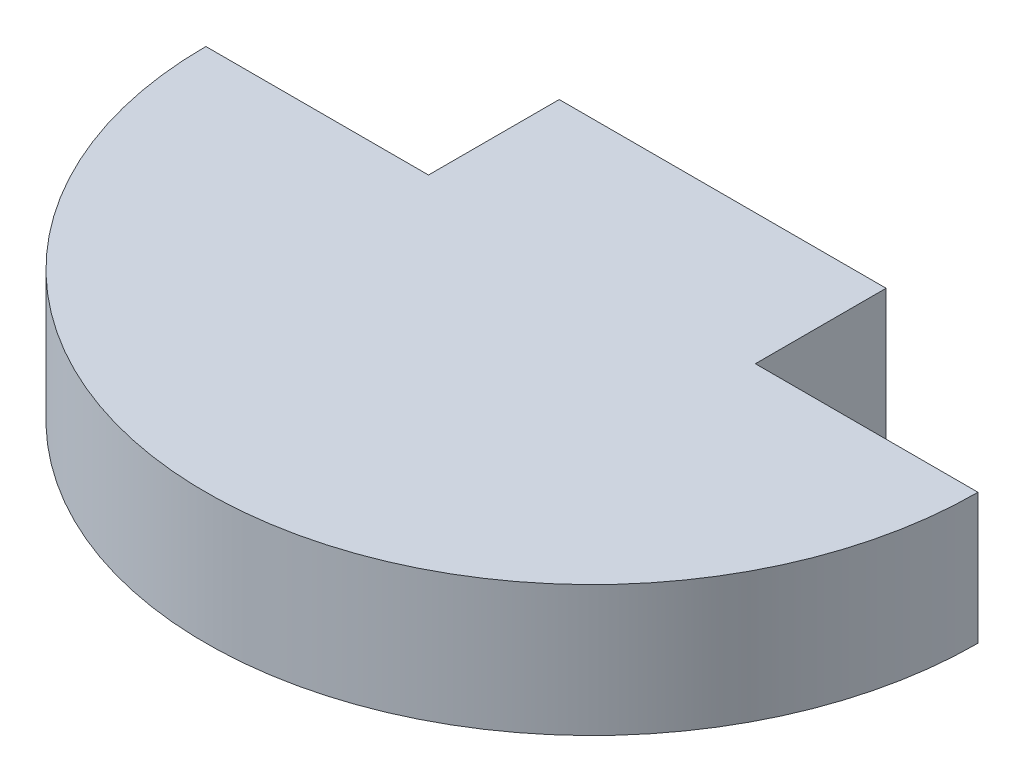
from build123d import *

# Parameters (mm, degrees)
SKETCH1_R           = 15
BOSS_EXTRUDE1_DEPTH = 5.08
SKETCH2_W           = 841.216063822
SKETCH2_H           = 769.249769976
CUT_EXTRUDE1_DEPTH  = 5.08
SKETCH3_W           = 12.7
SKETCH3_H           = 5.08
BOSS_EXTRUDE2_DEPTH = 5.08


with BuildPart() as part:
    # Sketch1 → Boss-Extrude1 (new body)
    with BuildSketch(Plane(origin=(0, 0, 0), x_dir=(1, 0, 0), z_dir=(0, 1, 0))):
        Circle(SKETCH1_R)
    extrude(amount=BOSS_EXTRUDE1_DEPTH)

    # Sketch2 → Cut-Extrude1 (cut)
    with BuildSketch(Plane(origin=(0, 5.08, 0), x_dir=(1, 0, 0), z_dir=(0, 1, 0))):
        with Locations((-405.608031911, 384.624884988)):
            Rectangle(SKETCH2_W, SKETCH2_H)
    extrude(amount=-CUT_EXTRUDE1_DEPTH, mode=Mode.SUBTRACT)

    # Sketch3 → Boss-Extrude2 (add)
    with BuildSketch(Plane(origin=(0, 0, 0), x_dir=(-1, 0, 0), z_dir=(0, 0, -1))):
        with Locations((0, 2.54)):
            Rectangle(SKETCH3_W, SKETCH3_H)
    extrude(amount=BOSS_EXTRUDE2_DEPTH)


solid = part.part
